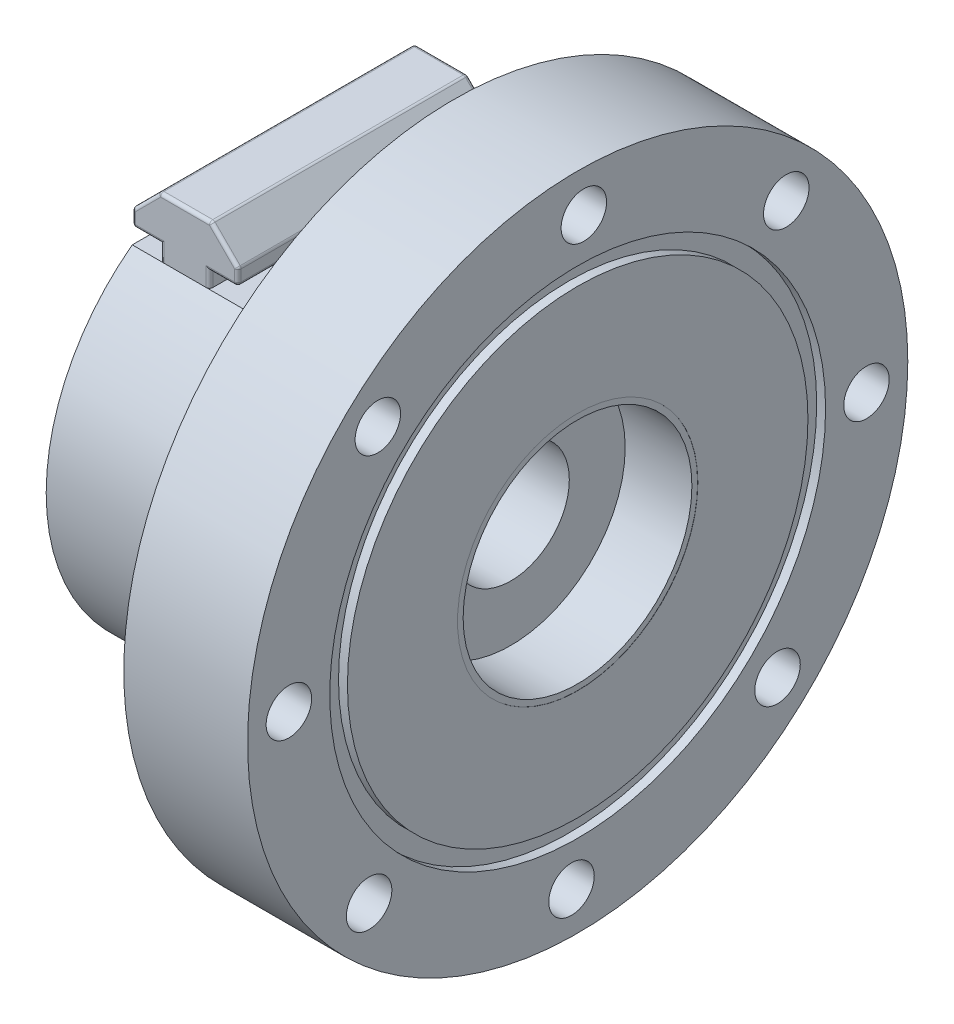
from build123d import *

# Parameters (mm, degrees)
M6_CLEARANCE_HOLE1_D = 7
SKETCH4_W            = 29.717000002
SKETCH4_H            = 66.04
CUT_EXTRUDE1_DEPTH   = 6.5786
BOSS_EXTRUDE1_DEPTH  = 39.556176
FILLET1_R            = 0.508
FILLET1_OF_MIRROR1_R = 0.508


with BuildPart() as part:
    # Main sketch → Revolve1 (revolve)
    with BuildSketch(Plane.XY):
        Polygon((0, 9.000000034), (0, 20.074999982), (-8.000000002, 20.074999982), (-8.000000002, 22.614999982), (-13.080000002, 22.614999982), (-13.080000002, 33.02), (-8.000000002, 33.02), (16.637, 33.02), (16.637, 50.8), (35.687, 50.8), (35.687, 38.1508), (34.3154, 38.1508), (34.3154, 35.433), (35.687, 35.433), (35.687, 18.4912), (35.6616, 18.4912), (35.6616, 17.6022), (25.4, 17.6022), (25.4, 9.000000034), align=None)
    revolve(axis=Axis((71.950113838, 0, 0), (-1, 0, 0)))

    # M6 Clearance Hole1 (through all)
    with Locations(Plane(origin=(35.687, 0, 0), x_dir=(0, 0, -1), z_dir=(1, 0, 0))):
        with Locations((0, 0), (-44.439876155, 0.948634466), (-32.094523648, -30.75295192), (-0.948634466, -44.439876155), (30.75295192, -32.094523648), (44.439876155, -0.948634466), (32.094523648, 30.75295192), (0.948634466, 44.439876155), (-30.75295192, 32.094523648)):
            Hole(M6_CLEARANCE_HOLE1_D / 2)

    # Sketch4 → Cut-Extrude1 (cut)
    with BuildSketch(Plane(origin=(0, 33.02, 0), x_dir=(1, 0, 0), z_dir=(0, 1, 0))):
        with Locations((1.778499999, 0)):
            Rectangle(SKETCH4_W, SKETCH4_H)
    cut_extrude1 = extrude(amount=-CUT_EXTRUDE1_DEPTH, mode=Mode.SUBTRACT)

    # Sketch5 → Boss-Extrude1 (add)
    with BuildSketch(Plane(origin=(0, 0, 19.778088028), x_dir=(-1, 0, 0), z_dir=(0, 0, -1))):
        Polygon((1.191199802, 26.4414), (1.191199802, 28.868399972), (-3.175999998, 28.868399972), (-3.175999998, 31.327400134), (0.988799902, 35.492200034), (8.915200102, 35.492200034), (13.080000002, 31.327400134), (13.080000002, 28.868399972), (8.712800202, 28.868399972), (8.712800202, 26.4414), align=None)
    boss_extrude1 = extrude(amount=BOSS_EXTRUDE1_DEPTH)

    # Fillet1
    fillet1_edges = [part.edges().sort_by_distance(p)[0] for p in [
        (-8.712800202, 27.654899986, -19.778087972),
        (-8.712800202, 27.654899986, 19.778088028),
        (-10.896400102, 28.868399972, -19.778087972),
        (-10.896400102, 28.868399972, 19.778088028),
        (-13.080000002, 30.097900053, -19.778087972),
        (-13.080000002, 28.868399972, 2.8e-08),
        (-13.080000002, 30.097900053, 19.778088028),
        (-10.997600052, 33.409800084, -19.778087972),
        (-13.080000002, 31.327400134, 2.8e-08),
        (-10.997600052, 33.409800084, 19.778088028),
        (-8.915200102, 35.492200034, 2.8e-08),
        (-0.988799902, 35.492200034, 2.8e-08),
        (3.175999998, 31.327400134, 2.8e-08),
        (3.175999998, 28.868399972, 2.8e-08),
        (-1.191199802, 27.654899986, 19.778088028),
        (0.992400098, 28.868399972, 19.778088028),
        (3.175999998, 30.097900053, 19.778088028),
        (1.093600048, 33.409800084, 19.778088028),
        (-4.952000002, 35.492200034, 19.778088028),
        (-4.952000002, 35.492200034, -19.778087972),
        (1.093600048, 33.409800084, -19.778087972),
        (3.175999998, 30.097900053, -19.778087972),
        (0.992400098, 28.868399972, -19.778087972),
        (-1.191199802, 27.654899986, -19.778087972),
    ]]
    fillet(fillet1_edges, radius=FILLET1_R)

    # Mirror1: Cut-Extrude1, Boss-Extrude1 across plane
    add(cut_extrude1.mirror(Plane.ZX), mode=Mode.SUBTRACT)
    add(boss_extrude1.mirror(Plane.ZX))

    # Fillet1 of Mirror1
    fillet1_of_mirror1_edges = [part.edges().sort_by_distance(p)[0] for p in [
        (-8.712800202, -27.654899986, -19.778087972),
        (-8.712800202, -27.654899986, 19.778088028),
        (-10.896400102, -28.868399972, -19.778087972),
        (-10.896400102, -28.868399972, 19.778088028),
        (-13.080000002, -30.097900053, -19.778087972),
        (-13.080000002, -28.868399972, 2.8e-08),
        (-13.080000002, -30.097900053, 19.778088028),
        (-10.997600052, -33.409800084, -19.778087972),
        (-13.080000002, -31.327400134, 2.8e-08),
        (-10.997600052, -33.409800084, 19.778088028),
        (-8.915200102, -35.492200034, 2.8e-08),
        (-0.988799902, -35.492200034, 2.8e-08),
        (3.175999998, -31.327400134, 2.8e-08),
        (3.175999998, -28.868399972, 2.8e-08),
        (-1.191199802, -27.654899986, 19.778088028),
        (0.992400098, -28.868399972, 19.778088028),
        (3.175999998, -30.097900053, 19.778088028),
        (1.093600048, -33.409800084, 19.778088028),
        (-4.952000002, -35.492200034, 19.778088028),
        (-4.952000002, -35.492200034, -19.778087972),
        (1.093600048, -33.409800084, -19.778087972),
        (3.175999998, -30.097900053, -19.778087972),
        (0.992400098, -28.868399972, -19.778087972),
        (-1.191199802, -27.654899986, -19.778087972),
    ]]
    fillet(fillet1_of_mirror1_edges, radius=FILLET1_OF_MIRROR1_R)


solid = part.part
